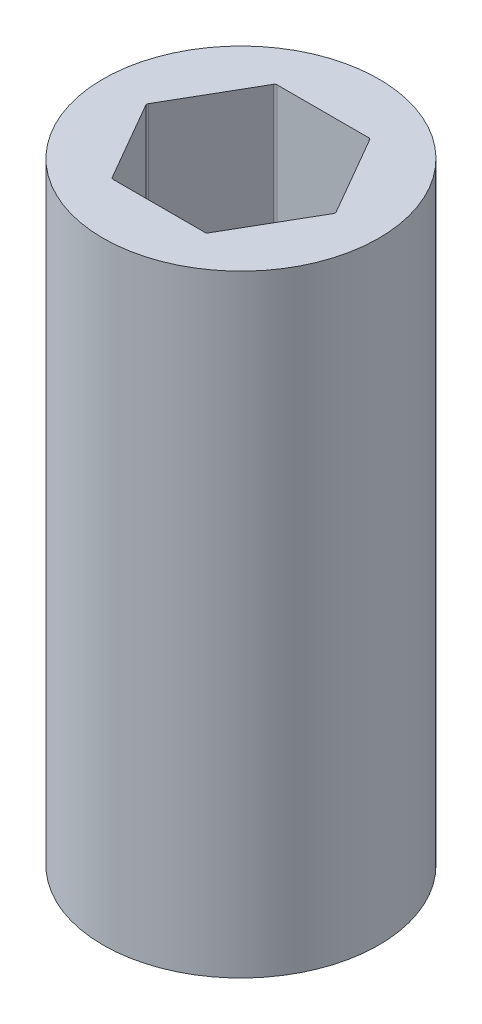
from build123d import *

# Parameters (mm, degrees)
SKETCH1_R           = 11.1125
BOSS_EXTRUDE1_DEPTH = 49.3268
FILLET1_R           = 0.2


with BuildPart() as part:
    # Sketch1 → Boss-Extrude1 (new body)
    with BuildSketch(Plane(origin=(0, 0, 0), x_dir=(1, 0, 0), z_dir=(0, 1, 0))):
        Circle(SKETCH1_R)
        Polygon((7.625642355, 0), (3.812821178, 6.604), (-3.812821178, 6.604), (-7.625642355, 0), (-3.812821178, -6.604), (3.812821178, -6.604), align=None, mode=Mode.SUBTRACT)
    extrude(amount=BOSS_EXTRUDE1_DEPTH)

    # Fillet1
    fillet1_edges = [part.edges().sort_by_distance(p)[0] for p in [
        (7.625642355, 24.6634, 0),
        (3.812821178, 24.6634, -6.604),
        (-3.812821178, 24.6634, -6.604),
        (-7.625642355, 24.6634, 0),
        (-3.812821178, 24.6634, 6.604),
        (3.812821178, 24.6634, 6.604),
    ]]
    fillet(fillet1_edges, radius=FILLET1_R)


solid = part.part
